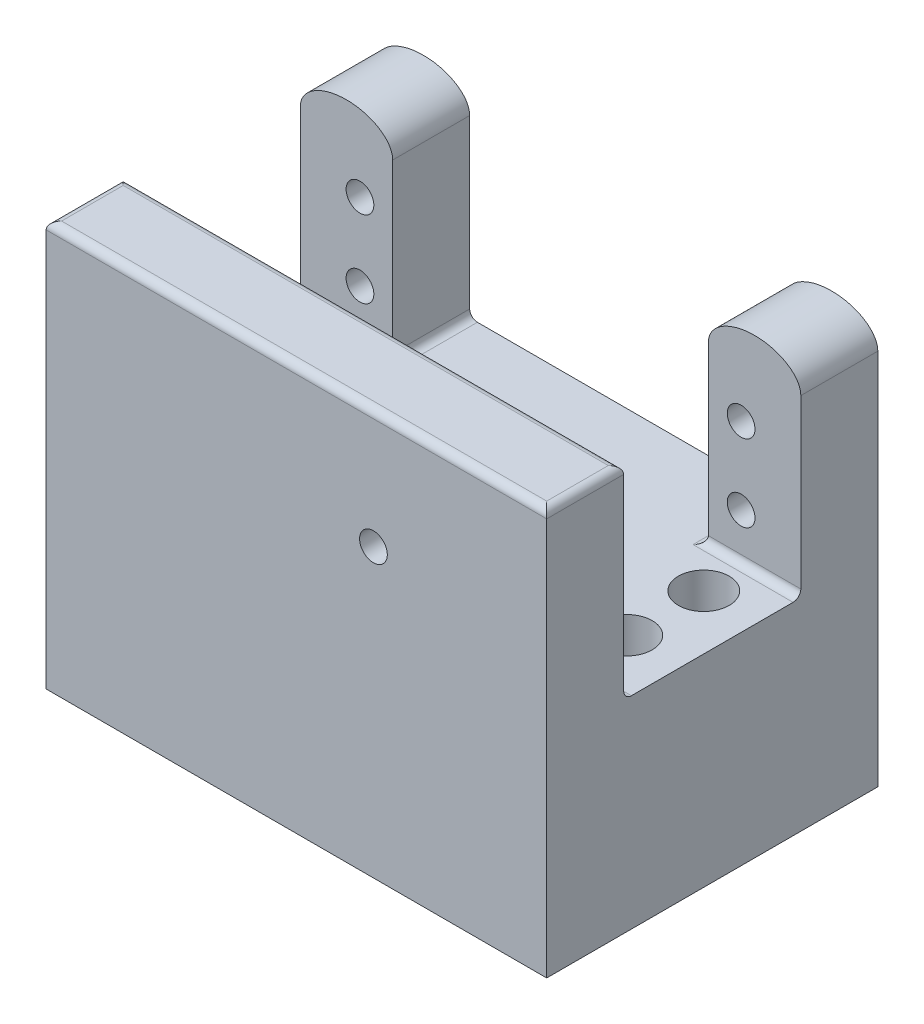
from build123d import *

# Parameters (mm, degrees)
BOSS_EXTRUDE1_DEPTH            = 10
SKETCH2_W                      = 12
SKETCH2_H                      = 12.25
BOSS_EXTRUDE2_DEPTH            = 23
SKETCH4_W                      = 65
SKETCH4_H                      = 38.636969104
BOSS_EXTRUDE3_DEPTH            = 10
F_3_6_3_6_DIAMETER_HOLE1_D     = 3.6
F_3_6_3_6_DIAMETER_HOLE1_DEPTH = 10
F_3_6_3_6_DIAMETER_HOLE1_TIP   = 1.081549114
SKETCH21_W                     = 41
SKETCH21_H                     = 12.25
BOSS_EXTRUDE4_DEPTH            = 33
SKETCH23_W                     = 65
SKETCH23_H                     = 43
BOSS_EXTRUDE6_DEPTH            = 14
FILLET1_R                      = 1
F_6_6_6_6_DIAMETER_HOLE1_D     = 6.6
SKETCH28_R                     = 1.8
CUT_EXTRUDE1_DEPTH             = 44.0000001


with BuildPart() as part:
    # Sketch1 → Boss-Extrude1 (new body)
    with BuildSketch(Plane.XY):
        with BuildLine():
            Line((-6, 14.302325581), (-6, -20.697674419))
            Line((-6, -20.697674419), (6, -20.697674419))
            Line((6, -20.697674419), (6, 14.302325581))
            add(Edge.make_bspline(
                [(6, 14.302325581), (6, 18.078005618), (0, 18.078005618), (-6, 18.078005618), (-6, 14.302325581)],
                knots=[0, 0, 0, 1.570796327, 1.570796327, 3.141592654, 3.141592654, 3.141592654], degree=2, weights=[1, 0.707106781, 1, 0.707106781, 1]))
        make_face()
    boss_extrude1 = extrude(amount=BOSS_EXTRUDE1_DEPTH)

    # Sketch2 → Boss-Extrude2 (add)
    with BuildSketch(Plane.XY.offset(10)):
        with Locations((0, -14.572674419)):
            Rectangle(SKETCH2_W, SKETCH2_H)
    boss_extrude2 = extrude(amount=BOSS_EXTRUDE2_DEPTH)

    # Sketch4 → Boss-Extrude3 (add)
    with BuildSketch(Plane.XY.offset(33)):
        with Locations((-26.5, -1.379189867)):
            Rectangle(SKETCH4_W, SKETCH4_H)
    extrude(amount=BOSS_EXTRUDE3_DEPTH)

    # Mirror2: Boss-Extrude2 across plane
    add(boss_extrude2.mirror(Plane.ZY.offset(26.5)))

    # Mirror3: Boss-Extrude1 across plane
    add(boss_extrude1.mirror(Plane.ZY.offset(26.5)))

    # Ø3.6 (3.6) Diameter Hole1
    with Locations(Plane(origin=(0, 0, 0), x_dir=(-1, 0, 0), z_dir=(0, 0, -1))):
        with Locations((1.75, 7.55218084), (1.75, -2.44781916), (51.25, 8), (51.25, -2)):
            Hole(F_3_6_3_6_DIAMETER_HOLE1_D / 2, depth=F_3_6_3_6_DIAMETER_HOLE1_DEPTH)
            with Locations((0, 0, -(F_3_6_3_6_DIAMETER_HOLE1_DEPTH + F_3_6_3_6_DIAMETER_HOLE1_TIP / 2))):  # 118° drill point
                Cone(0, F_3_6_3_6_DIAMETER_HOLE1_D / 2, F_3_6_3_6_DIAMETER_HOLE1_TIP, mode=Mode.SUBTRACT)

    # Sketch21 → Boss-Extrude4 (add)
    with BuildSketch(Plane(origin=(0, 0, 33), x_dir=(-1, 0, 0), z_dir=(0, 0, -1))):
        with Locations((26.5, -14.572674419)):
            Rectangle(SKETCH21_W, SKETCH21_H)
    extrude(amount=BOSS_EXTRUDE4_DEPTH)

    # Sketch23 → Boss-Extrude6 (add)
    with BuildSketch(Plane.XZ.offset(20.697674419)):
        with Locations((-26.5, 21.5)):
            Rectangle(SKETCH23_W, SKETCH23_H)
    extrude(amount=BOSS_EXTRUDE6_DEPTH)

    # Fillet1
    fillet1_edges = [part.edges().sort_by_distance(p)[0] for p in [
        (-26.5, -8.447674419, 33),
        (0, -8.447674419, 10),
        (-26.5, 17.939294685, 33),
        (6, 17.939294685, 38),
        (-59, 17.939294685, 38),
        (-26.5, 17.939294685, 43),
        (-53, -8.447674419, 10),
        (-47, -8.447674419, 5),
        (-6, -8.447674419, 5),
    ]]
    fillet(fillet1_edges, radius=FILLET1_R)

    # Ø6.6 (6.6) Diameter Hole1 (through all)
    with Locations(Plane(origin=(0, -34.697674419, 0), x_dir=(-1, 0, 0), z_dir=(0, -1, 0))):
        with Locations((1.1, -15.5), (1.1, -25.5), (51.9, -15.5), (51.9, -25.5)):
            Hole(F_6_6_6_6_DIAMETER_HOLE1_D / 2)

    # Sketch28 → Cut-Extrude1 (cut, through all)
    with BuildSketch(Plane.XY.offset(43)):
        with Locations((-16.5, 2.553012267)):
            Circle(SKETCH28_R)
    extrude(amount=-CUT_EXTRUDE1_DEPTH, mode=Mode.SUBTRACT)


solid = part.part
